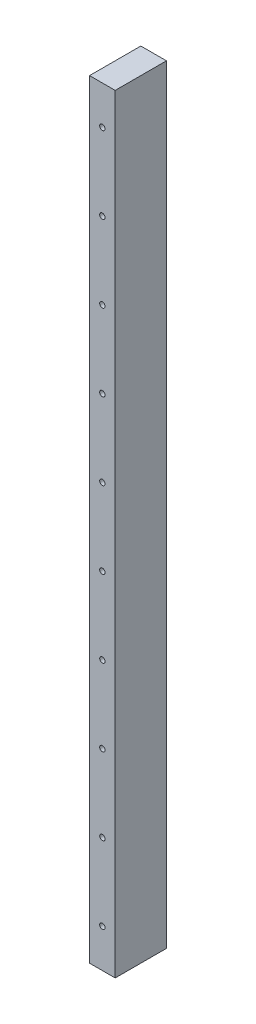
from build123d import *

# Parameters (mm, degrees)
SKETCH_1_W                  = 40
SKETCH_1_H                  = 600
EXTRUDE_1_DEPTH             = 20
HOLE_WIZARD_9_0_9_1_D       = 9
HOLE_WIZARD_9_0_9_1_DEPTH   = 15
HOLE_WIZARD_9_0_9_1_TIP     = 2.703872786
HOLE_WIZARD_4_2_4_2_1_D     = 4.2
HOLE_WIZARD_4_2_4_2_1_DEPTH = 12.4
HOLE_WIZARD_4_2_4_2_1_TIP   = 1.2618073


with BuildPart() as part:
    # 草图1 → 凸台-拉伸1 (new body)
    with BuildSketch(Plane(origin=(-230, 0, 0), x_dir=(0, 0, -1), z_dir=(1, 0, 0))):
        with Locations((155, 1520)):
            Rectangle(SKETCH_1_W, SKETCH_1_H)
    extrude(amount=-EXTRUDE_1_DEPTH)

    # Ø9.0 (9) 直径孔1
    with Locations(Plane(origin=(0, 0, -175), x_dir=(-1, 0, 0), z_dir=(0, 0, -1))):
        with Locations((240, 1250), (240, 1430), (240, 1610), (240, 1790)):
            Hole(HOLE_WIZARD_9_0_9_1_D / 2, depth=HOLE_WIZARD_9_0_9_1_DEPTH)
            with Locations((0, 0, -(HOLE_WIZARD_9_0_9_1_DEPTH + HOLE_WIZARD_9_0_9_1_TIP / 2))):  # 118° drill point
                Cone(0, HOLE_WIZARD_9_0_9_1_D / 2, HOLE_WIZARD_9_0_9_1_TIP, mode=Mode.SUBTRACT)

    # Ø4.2 (4.2) 直径孔1
    with Locations(Plane.XY.offset(-135)):
        with Locations((-240, 1610), (-240, 1250), (-240, 1310), (-240, 1370), (-240, 1430), (-240, 1490), (-240, 1550), (-240, 1670), (-240, 1730), (-240, 1790)):
            Hole(HOLE_WIZARD_4_2_4_2_1_D / 2, depth=HOLE_WIZARD_4_2_4_2_1_DEPTH)
            with Locations((0, 0, -(HOLE_WIZARD_4_2_4_2_1_DEPTH + HOLE_WIZARD_4_2_4_2_1_TIP / 2))):  # 118° drill point
                Cone(0, HOLE_WIZARD_4_2_4_2_1_D / 2, HOLE_WIZARD_4_2_4_2_1_TIP, mode=Mode.SUBTRACT)


solid = part.part
